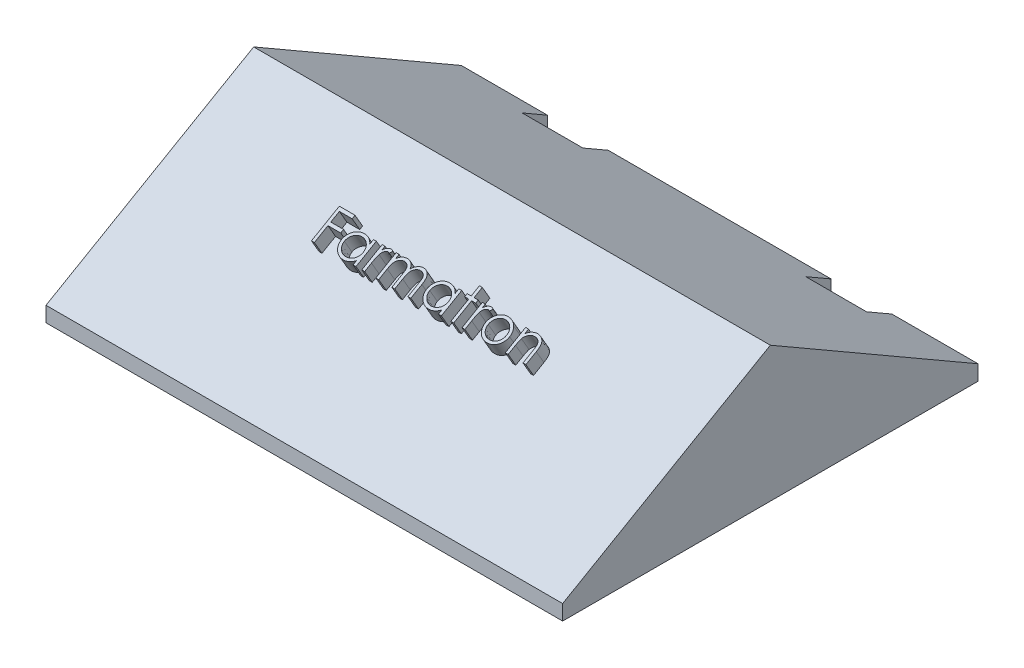
from build123d import *

# Parameters (mm, degrees)
SKETCH1_W                      = 102
SKETCH1_H                      = 82
BOSS_EXTRUDE1_DEPTH            = 3
SKETCH2_W                      = 91
SKETCH2_H                      = 71
BOSS_EXTRUDE2_DEPTH            = 3
BOSS_EXTRUDE4_DEPTH            = 102
BOSS_EXTRUDE5_DEPTH            = 3
SKETCH7_W                      = 12
SKETCH7_H                      = 7
CUT_EXTRUDE1_DEPTH             = 10
CUT_EXTRUDE1_DIRECTION_2_REACH = 28.671


with BuildPart() as part:
    # Sketch1 → Boss-Extrude1 (new body)
    with BuildSketch(Plane(origin=(0, 0, 0), x_dir=(1, 0, 0), z_dir=(0, 1, 0))):
        Rectangle(SKETCH1_W, SKETCH1_H)
    extrude(amount=BOSS_EXTRUDE1_DEPTH)

    # Sketch2 → Boss-Extrude2 (add)
    with BuildSketch(Plane.XZ):
        Rectangle(SKETCH2_W, SKETCH2_H)
    extrude(amount=BOSS_EXTRUDE2_DEPTH)

    # Sketch5 → Boss-Extrude4 (add)
    with BuildSketch(Plane.ZY.offset(51)):
        Polygon((-41, 3), (41, 3), (0, 26.671361037), align=None)
    extrude(amount=-BOSS_EXTRUDE4_DEPTH)

    # Sketch6 → Boss-Extrude5 (add)
    with BuildSketch(Plane(origin=(0, 20.003520778, 11.549038106), x_dir=(1, 0, 0), z_dir=(0, 0.866025404, 0.5))):
        Polygon((-19.990396317, -1.212207797), (-16.896806574, -1.212207797), (-16.896806574, -1.863489848), (-19.420524523, -1.863489848), (-19.420524523, -3.817336002), (-16.896806574, -3.817336002), (-16.896806574, -4.468618053), (-19.420524523, -4.468618053), (-19.420524523, -7.562207797), (-19.990396317, -7.562207797), align=None)
        with BuildLine():
            Line((-11.198088625, -2.921823181), (-11.198088625, -7.562207797))
            Line((-11.198088625, -7.562207797), (-11.76796042, -7.562207797))
            Line((-11.76796042, -7.562207797), (-11.76796042, -6.75955355))
            add(Edge.make_bspline(
                [(-11.76796042, -6.75955355), (-11.832220226, -6.832196813), (-11.957624045, -6.973961055), (-12.167067216, -7.159167282), (-12.389078053, -7.312253666), (-12.622579022, -7.435897084), (-12.867359263, -7.528774101), (-13.122876164, -7.594788989), (-13.389233955, -7.63723209), (-13.57112037, -7.641470301), (-13.663292952, -7.643618053)],
                knots=[0, 0, 0, 0, 0.000290762, 0.000567426, 0.000836293, 0.001098035, 0.001358135, 0.001619769, 0.001888723, 0.002165047, 0.002165047, 0.002165047, 0.002165047], degree=3))
            add(Edge.make_bspline(
                [(-13.663292952, -7.643618053), (-13.745240525, -7.641393063), (-13.906844769, -7.637005285), (-14.144568951, -7.602965106), (-14.373336318, -7.548299549), (-14.593363043, -7.472279364), (-14.803225364, -7.371439873), (-15.004720111, -7.250715038), (-15.196803423, -7.106949532), (-15.376547501, -6.942596966), (-15.542068416, -6.764080346), (-15.687322439, -6.57367914), (-15.808431599, -6.372216674), (-15.909705174, -6.162243667), (-15.987712827, -5.942143741), (-16.042093563, -5.712678022), (-16.076094088, -5.474117823), (-16.080480053, -5.311667545), (-16.08270401, -5.229295136)],
                knots=[0, 0, 0, 0, 0.00024577, 0.000484669, 0.00071884, 0.00095056, 0.001181567, 0.001416081, 0.001654206, 0.001900039, 0.002145792, 0.002383666, 0.00261709, 0.002849793, 0.003081935, 0.003316107, 0.003556266, 0.003803306, 0.003803306, 0.003803306, 0.003803306], degree=3))
            add(Edge.make_bspline(
                [(-16.08270401, -5.229295136), (-16.080430762, -5.148625274), (-16.075936673, -4.989145308), (-16.04245726, -4.754596814), (-15.986158144, -4.528685112), (-15.907149906, -4.312137515), (-15.805836645, -4.104691995), (-15.682595687, -3.906201836), (-15.537418132, -3.716120215), (-15.370045908, -3.538916703), (-15.188735682, -3.375230732), (-14.994772699, -3.23297432), (-14.792981889, -3.110116609), (-14.580233284, -3.012773873), (-14.359675822, -2.934017355), (-14.129345999, -2.87952897), (-13.890202135, -2.847420973), (-13.727840814, -2.842771387), (-13.645484458, -2.840412925)],
                knots=[0, 0, 0, 0, 0.000241958, 0.000478337, 0.000709106, 0.000939284, 0.001168551, 0.00140047, 0.001639115, 0.001884802, 0.002130726, 0.002370895, 0.002605409, 0.002838177, 0.003071519, 0.003306928, 0.003546915, 0.003793955, 0.003793955, 0.003793955, 0.003793955], degree=3))
            add(Edge.make_bspline(
                [(-13.645484458, -2.840412925), (-13.550779, -2.843021417), (-13.365066065, -2.848136547), (-13.093416677, -2.890704638), (-12.836433124, -2.962620143), (-12.592131657, -3.060441889), (-12.361389555, -3.190433155), (-12.146391284, -3.354408227), (-11.944886764, -3.551332952), (-11.82808252, -3.702590758), (-11.76796042, -3.780446979)],
                knots=[0, 0, 0, 0, 0.000284009, 0.000556928, 0.000822345, 0.001083124, 0.001344564, 0.001614238, 0.001892186, 0.002187002, 0.002187002, 0.002187002, 0.002187002], degree=3))
            Line((-11.76796042, -3.780446979), (-11.76796042, -2.921823181))
            Line((-11.76796042, -2.921823181), (-11.198088625, -2.921823181))
        make_face()
        with BuildLine():
            add(Edge.make_bspline(
                [(-13.637852247, -3.41028472), (-13.721153974, -3.413248605), (-13.885578334, -3.419098844), (-14.126958166, -3.464770757), (-14.357941075, -3.540761378), (-14.57737181, -3.644687113), (-14.781784145, -3.775367821), (-14.964471234, -3.933430902), (-15.126927278, -4.11456377), (-15.263557986, -4.317949028), (-15.374937887, -4.535986422), (-15.453255217, -4.763905045), (-15.504906566, -4.997594076), (-15.510183453, -5.156094949), (-15.512832215, -5.235655313)],
                knots=[0, 0, 0, 0, 0.000249786, 0.000493037, 0.00073399, 0.000977521, 0.001219572, 0.001459505, 0.001700041, 0.001947359, 0.002192545, 0.00243231, 0.002668812, 0.002907172, 0.002907172, 0.002907172, 0.002907172], degree=3))
            add(Edge.make_bspline(
                [(-15.512832215, -5.235655313), (-15.509448766, -5.314740221), (-15.502695129, -5.472600053), (-15.454161726, -5.706607671), (-15.372736813, -5.934580004), (-15.261626214, -6.154582092), (-15.122494766, -6.358841817), (-14.961225353, -6.543427468), (-14.776258414, -6.702158578), (-14.571375652, -6.835032462), (-14.352558334, -6.942370178), (-14.122445344, -7.01705641), (-13.8853624, -7.065276098), (-13.72415888, -7.070908506), (-13.642940388, -7.073746258)],
                knots=[0, 0, 0, 0, 0.000237176, 0.000473422, 0.000713608, 0.000961638, 0.001210723, 0.001453162, 0.001694889, 0.001939391, 0.002184022, 0.002423766, 0.002663507, 0.002906945, 0.002906945, 0.002906945, 0.002906945], degree=3))
            add(Edge.make_bspline(
                [(-13.642940388, -7.073746258), (-13.560487447, -7.070734609), (-13.396496726, -7.064744739), (-13.154400785, -7.0188773), (-12.919459923, -6.943096766), (-12.694874523, -6.838051207), (-12.485658114, -6.707862862), (-12.297883393, -6.555449997), (-12.139104422, -6.378188505), (-12.00449783, -6.183376941), (-11.898951003, -5.969813747), (-11.822068724, -5.742421715), (-11.776613781, -5.501192929), (-11.770884757, -5.336339805), (-11.76796042, -5.252191771)],
                knots=[0, 0, 0, 0, 0.000247246, 0.000491749, 0.00073633, 0.000986158, 0.001233581, 0.001473979, 0.001709031, 0.001945074, 0.002182295, 0.002421234, 0.002663235, 0.00291556, 0.00291556, 0.00291556, 0.00291556], degree=3))
            add(Edge.make_bspline(
                [(-11.76796042, -5.252191771), (-11.769701511, -5.18807885), (-11.773128529, -5.061884332), (-11.799309705, -4.876595836), (-11.8409565, -4.699278933), (-11.899641694, -4.529747197), (-11.976733024, -4.368937955), (-12.069711114, -4.215696562), (-12.180211001, -4.070820021), (-12.306453893, -3.936303306), (-12.444639332, -3.813609582), (-12.590860855, -3.704091602), (-12.746850868, -3.614123401), (-12.909986063, -3.539662808), (-13.080549484, -3.480409779), (-13.259929037, -3.440880677), (-13.446218057, -3.413738381), (-13.573301614, -3.411448061), (-13.637852247, -3.41028472)],
                knots=[0, 0, 0, 0, 0.000192284, 0.000378475, 0.000560202, 0.000738015, 0.000915535, 0.001094205, 0.001274839, 0.001461134, 0.001646738, 0.001828644, 0.002008199, 0.002185797, 0.002366014, 0.002548692, 0.002736143, 0.002929643, 0.002929643, 0.002929643, 0.002929643], degree=3))
        make_face(mode=Mode.SUBTRACT)
        with BuildLine():
            Line((-10.058345035, -2.921823181), (-9.488473241, -2.921823181))
            Line((-9.488473241, -2.921823181), (-9.488473241, -3.604906114))
            add(Edge.make_bspline(
                [(-9.488473241, -3.604906114), (-9.446402207, -3.541304825), (-9.365941682, -3.419667855), (-9.232205367, -3.258796409), (-9.095220752, -3.125600539), (-8.954332055, -3.019458441), (-8.808503216, -2.939968925), (-8.660934747, -2.88174299), (-8.509304966, -2.847312718), (-8.407411189, -2.842715937), (-8.356361862, -2.840412925)],
                knots=[0, 0, 0, 0, 0.000228641, 0.000437274, 0.000626196, 0.00080072, 0.000964674, 0.001122945, 0.001275403, 0.001428476, 0.001428476, 0.001428476, 0.001428476], degree=3))
            add(Edge.make_bspline(
                [(-8.356361862, -2.840412925), (-8.31676267, -2.84257288), (-8.235284758, -2.847017129), (-8.111944917, -2.878242482), (-7.984866083, -2.928095466), (-7.902964894, -2.974977013), (-7.860268112, -2.999417332)],
                knots=[0, 0, 0, 0, 0.000118736, 0.000244307, 0.000379658, 0.000527066, 0.000527066, 0.000527066, 0.000527066], degree=3))
            Line((-7.860268112, -2.999417332), (-8.173188785, -3.492967011))
            add(Edge.make_bspline(
                [(-8.173188785, -3.492967011), (-8.200600867, -3.480738243), (-8.252634244, -3.457525699), (-8.328751815, -3.430053767), (-8.398930811, -3.413877748), (-8.443641267, -3.41142716), (-8.464484859, -3.41028472)],
                knots=[0, 0, 0, 0, 9.0027e-05, 0.000170889, 0.000242497, 0.000305034, 0.000305034, 0.000305034, 0.000305034], degree=3))
            add(Edge.make_bspline(
                [(-8.464484859, -3.41028472), (-8.510215261, -3.413332788), (-8.603492026, -3.419549962), (-8.740442475, -3.468424656), (-8.873333833, -3.547391878), (-8.978873849, -3.634969466), (-9.060593365, -3.71942047), (-9.118904917, -3.793168286), (-9.172395044, -3.875860947), (-9.223503872, -3.966084801), (-9.270069863, -4.065380379), (-9.313530477, -4.172755638), (-9.352825843, -4.288334943), (-9.375232715, -4.368857515), (-9.38671042, -4.410104431)],
                knots=[0, 0, 0, 0, 0.000136961, 0.000279361, 0.000430989, 0.000599071, 0.000689036, 0.000783201, 0.000880576, 0.000984237, 0.001094053, 0.001209325, 0.001331612, 0.001460037, 0.001460037, 0.001460037, 0.001460037], degree=3))
            add(Edge.make_bspline(
                [(-9.38671042, -4.410104431), (-9.395296334, -4.446893018), (-9.41431348, -4.528376941), (-9.432803842, -4.665080693), (-9.451072824, -4.826595045), (-9.463948117, -5.013369578), (-9.475882565, -5.224937869), (-9.482613714, -5.461622228), (-9.488243698, -5.723665593), (-9.488394405, -5.90686192), (-9.488473241, -6.002692572)],
                knots=[0, 0, 0, 0, 0.000113275, 0.000250896, 0.000413424, 0.000600936, 0.000812404, 0.001049125, 0.001311214, 0.001598697, 0.001598697, 0.001598697, 0.001598697], degree=3))
            Line((-9.488473241, -6.002692572), (-9.488473241, -7.562207797))
            Line((-9.488473241, -7.562207797), (-10.058345035, -7.562207797))
            Line((-10.058345035, -7.562207797), (-10.058345035, -2.921823181))
        make_face()
        with BuildLine():
            Line((-7.290396317, -2.921823181), (-6.720524523, -2.921823181))
            Line((-6.720524523, -2.921823181), (-6.720524523, -3.728293534))
            add(Edge.make_bspline(
                [(-6.720524523, -3.728293534), (-6.669209356, -3.657740314), (-6.570884578, -3.52255358), (-6.409656894, -3.34440835), (-6.248591662, -3.193227269), (-6.13259824, -3.113865202), (-6.076874683, -3.075739447)],
                knots=[0, 0, 0, 0, 0.000261532, 0.000501121, 0.000719915, 0.000922205, 0.000922205, 0.000922205, 0.000922205], degree=3))
            add(Edge.make_bspline(
                [(-6.076874683, -3.075739447), (-6.000920224, -3.039443999), (-5.85033832, -2.967487226), (-5.611906298, -2.894492055), (-5.367930826, -2.849633657), (-5.203178781, -2.843498879), (-5.12030417, -2.840412925)],
                knots=[0, 0, 0, 0, 0.000252242, 0.000500077, 0.000745602, 0.000994118, 0.000994118, 0.000994118, 0.000994118], degree=3))
            add(Edge.make_bspline(
                [(-5.12030417, -2.840412925), (-5.064255448, -2.842309381), (-4.95333804, -2.846062366), (-4.788992619, -2.870482715), (-4.629591995, -2.912694201), (-4.47607797, -2.971490345), (-4.331441881, -3.042695049), (-4.198837193, -3.126242376), (-4.07977613, -3.220035641), (-3.974318866, -3.328310277), (-3.879487919, -3.454106677), (-3.792259155, -3.600817529), (-3.711659127, -3.771737142), (-3.666989038, -3.895773581), (-3.643471237, -3.961075986)],
                knots=[0, 0, 0, 0, 0.000168145, 0.000332749, 0.000497201, 0.000661865, 0.000825132, 0.000980059, 0.001131239, 0.001278762, 0.001432173, 0.001602768, 0.001789969, 0.001998105, 0.001998105, 0.001998105, 0.001998105], degree=3))
            add(Edge.make_bspline(
                [(-3.643471237, -3.961075986), (-3.61859511, -3.916218825), (-3.569642384, -3.827946232), (-3.487445014, -3.703017671), (-3.401324869, -3.586165349), (-3.310548003, -3.47729655), (-3.215434824, -3.376948896), (-3.115537712, -3.284790618), (-3.011425323, -3.200425944), (-2.866659402, -3.101868212), (-2.678313672, -2.997181783), (-2.440845235, -2.906415892), (-2.193829924, -2.850325202), (-2.026157814, -2.843738849), (-1.941488064, -2.840412925)],
                knots=[0, 0, 0, 0, 0.000153832, 0.00030272, 0.000448244, 0.000589125, 0.000727689, 0.000862717, 0.000996613, 0.001129277, 0.001387748, 0.001640998, 0.001889761, 0.002143522, 0.002143522, 0.002143522, 0.002143522], degree=3))
            add(Edge.make_bspline(
                [(-1.941488064, -2.840412925), (-1.863688839, -2.843347026), (-1.711428201, -2.849089346), (-1.489763733, -2.894180647), (-1.283040743, -2.971610093), (-1.091675191, -3.077262548), (-0.919028101, -3.210030494), (-0.768957083, -3.367998243), (-0.642373709, -3.55004843), (-0.559681035, -3.721302467), (-0.503591912, -3.872496571), (-0.469009387, -4.001322271), (-0.438457369, -4.143111517), (-0.413091395, -4.298033848), (-0.394552022, -4.466636523), (-0.380816581, -4.648643627), (-0.371520048, -4.844196615), (-0.370863145, -4.97911688), (-0.370524523, -5.04866613)],
                knots=[0, 0, 0, 0, 0.000233282, 0.000456556, 0.000675113, 0.000893181, 0.001109954, 0.001325893, 0.001544317, 0.00177244, 0.001894377, 0.002027698, 0.002172157, 0.002329416, 0.002498406, 0.002680844, 0.00287694, 0.003085569, 0.003085569, 0.003085569, 0.003085569], degree=3))
            Line((-0.370524523, -5.04866613), (-0.370524523, -7.562207797))
            Line((-0.370524523, -7.562207797), (-0.940396317, -7.562207797))
            Line((-0.940396317, -7.562207797), (-0.940396317, -5.046122059))
            add(Edge.make_bspline(
                [(-0.940396317, -5.046122059), (-0.940537619, -4.98675759), (-0.94080918, -4.872668107), (-0.945696198, -4.708924374), (-0.954904267, -4.559666069), (-0.965671398, -4.425096709), (-0.980628023, -4.304902478), (-0.999942785, -4.199324805), (-1.020403719, -4.107533175), (-1.05439616, -4.00577706), (-1.108730192, -3.893526821), (-1.191493334, -3.772471191), (-1.295760527, -3.667096025), (-1.416156811, -3.575622793), (-1.553223275, -3.501248616), (-1.704289272, -3.448133569), (-1.868416909, -3.41525349), (-1.982032539, -3.411976862), (-2.040706814, -3.41028472)],
                knots=[0, 0, 0, 0, 0.000178089, 0.000342261, 0.000491355, 0.000626676, 0.000747218, 0.000854507, 0.000948612, 0.001029062, 0.001175849, 0.001321223, 0.001466947, 0.001618576, 0.001773394, 0.001932718, 0.002097367, 0.002273203, 0.002273203, 0.002273203, 0.002273203], degree=3))
            add(Edge.make_bspline(
                [(-2.040706814, -3.41028472), (-2.112679446, -3.412854034), (-2.254924727, -3.417931975), (-2.462561538, -3.469773145), (-2.662080383, -3.547933028), (-2.847527838, -3.661203343), (-3.018121115, -3.796927089), (-3.164896064, -3.95830707), (-3.286148743, -4.140878509), (-3.368252385, -4.30987324), (-3.420121546, -4.461673517), (-3.454369665, -4.594293035), (-3.481009532, -4.745026736), (-3.505993207, -4.912861755), (-3.522299513, -5.098953368), (-3.537119274, -5.302440753), (-3.544051411, -5.523935937), (-3.545021072, -5.677472929), (-3.545524523, -5.757189768)],
                knots=[0, 0, 0, 0, 0.000215515, 0.00042594, 0.000638294, 0.000856228, 0.001075151, 0.001290351, 0.001507675, 0.001730699, 0.001851783, 0.00198846, 0.002141147, 0.002310786, 0.002497355, 0.002701361, 0.002922827, 0.003161983, 0.003161983, 0.003161983, 0.003161983], degree=3))
            Line((-3.545524523, -5.757189768), (-3.545524523, -7.562207797))
            Line((-3.545524523, -7.562207797), (-4.115396317, -7.562207797))
            Line((-4.115396317, -7.562207797), (-4.115396317, -5.202582396))
            add(Edge.make_bspline(
                [(-4.115396317, -5.202582396), (-4.115540428, -5.136010232), (-4.115817682, -5.00793208), (-4.120673286, -4.824265269), (-4.129901871, -4.657203881), (-4.140570866, -4.506942082), (-4.155920047, -4.373752957), (-4.173354901, -4.256922467), (-4.193944523, -4.156743505), (-4.228034743, -4.046864221), (-4.280130992, -3.925813403), (-4.363929696, -3.796743265), (-4.468446306, -3.683771145), (-4.591039181, -3.587325987), (-4.728935204, -3.507603585), (-4.881305089, -3.45016375), (-5.046776859, -3.416736825), (-5.160854983, -3.412475981), (-5.21952292, -3.41028472)],
                knots=[0, 0, 0, 0, 0.000199714, 0.000384229, 0.000551103, 0.000701639, 0.000836072, 0.00095319, 0.001055981, 0.001142488, 0.001297994, 0.001449708, 0.001601848, 0.001757598, 0.001916006, 0.00207784, 0.002243986, 0.002419899, 0.002419899, 0.002419899, 0.002419899], degree=3))
            add(Edge.make_bspline(
                [(-5.21952292, -3.41028472), (-5.288495189, -3.413061411), (-5.425954473, -3.41859526), (-5.627888046, -3.468405156), (-5.822897787, -3.546426835), (-6.00787274, -3.654666792), (-6.177824409, -3.788740835), (-6.326610837, -3.946429289), (-6.451692276, -4.125769678), (-6.534662855, -4.292982444), (-6.588181515, -4.440979671), (-6.623733051, -4.566802105), (-6.654284943, -4.706502555), (-6.676988954, -4.860512028), (-6.698906279, -5.027827442), (-6.709484126, -5.209282302), (-6.71977396, -5.404720947), (-6.720268198, -5.539653993), (-6.720524523, -5.609633678)],
                knots=[0, 0, 0, 0, 0.000206634, 0.000411815, 0.000620153, 0.000835052, 0.001052387, 0.001267452, 0.001483061, 0.001706059, 0.001825169, 0.001954817, 0.002098033, 0.002253835, 0.00242171, 0.002604055, 0.00279888, 0.003008781, 0.003008781, 0.003008781, 0.003008781], degree=3))
            Line((-6.720524523, -5.609633678), (-6.720524523, -7.562207797))
            Line((-6.720524523, -7.562207797), (-7.290396317, -7.562207797))
            Line((-7.290396317, -7.562207797), (-7.290396317, -2.921823181))
        make_face()
        with BuildLine():
            Line((5.653834452, -2.921823181), (5.653834452, -7.562207797))
            Line((5.653834452, -7.562207797), (5.083962657, -7.562207797))
            Line((5.083962657, -7.562207797), (5.083962657, -6.75955355))
            add(Edge.make_bspline(
                [(5.083962657, -6.75955355), (5.019702851, -6.832196813), (4.894299032, -6.973961055), (4.684855861, -7.159167282), (4.462845024, -7.312253666), (4.229344055, -7.435897084), (3.984563814, -7.528774101), (3.729046913, -7.594788989), (3.462689122, -7.63723209), (3.280802707, -7.641470301), (3.188630125, -7.643618053)],
                knots=[0, 0, 0, 0, 0.000290762, 0.000567426, 0.000836293, 0.001098035, 0.001358135, 0.001619769, 0.001888723, 0.002165047, 0.002165047, 0.002165047, 0.002165047], degree=3))
            add(Edge.make_bspline(
                [(3.188630125, -7.643618053), (3.106682552, -7.641393063), (2.945078308, -7.637005285), (2.707354126, -7.602965106), (2.478586759, -7.548299549), (2.258560034, -7.472279364), (2.048697713, -7.371439873), (1.847202966, -7.250715038), (1.655119654, -7.106949532), (1.475375576, -6.942596966), (1.309854661, -6.764080346), (1.164600638, -6.57367914), (1.043491478, -6.372216674), (0.942217903, -6.162243667), (0.86421025, -5.942143741), (0.809829513, -5.712678022), (0.775828989, -5.474117823), (0.771443024, -5.311667545), (0.769219067, -5.229295136)],
                knots=[0, 0, 0, 0, 0.00024577, 0.000484669, 0.00071884, 0.00095056, 0.001181567, 0.001416081, 0.001654206, 0.001900039, 0.002145792, 0.002383666, 0.00261709, 0.002849793, 0.003081935, 0.003316107, 0.003556266, 0.003803306, 0.003803306, 0.003803306, 0.003803306], degree=3))
            add(Edge.make_bspline(
                [(0.769219067, -5.229295136), (0.771492315, -5.148625274), (0.775986404, -4.989145308), (0.809465817, -4.754596814), (0.865764933, -4.528685112), (0.944773171, -4.312137515), (1.046086432, -4.104691995), (1.16932739, -3.906201836), (1.314504945, -3.716120215), (1.481877169, -3.538916703), (1.663187395, -3.375230732), (1.857150378, -3.23297432), (2.058941188, -3.110116609), (2.271689793, -3.012773873), (2.492247255, -2.934017355), (2.722577078, -2.87952897), (2.961720942, -2.847420973), (3.124082263, -2.842771387), (3.206438618, -2.840412925)],
                knots=[0, 0, 0, 0, 0.000241958, 0.000478337, 0.000709106, 0.000939284, 0.001168551, 0.00140047, 0.001639115, 0.001884802, 0.002130726, 0.002370895, 0.002605409, 0.002838177, 0.003071519, 0.003306928, 0.003546915, 0.003793955, 0.003793955, 0.003793955, 0.003793955], degree=3))
            add(Edge.make_bspline(
                [(3.206438618, -2.840412925), (3.301144077, -2.843021417), (3.486857012, -2.848136547), (3.7585064, -2.890704638), (4.015489953, -2.962620143), (4.25979142, -3.060441889), (4.490533522, -3.190433155), (4.705531793, -3.354408227), (4.907036313, -3.551332952), (5.023840556, -3.702590758), (5.083962657, -3.780446979)],
                knots=[0, 0, 0, 0, 0.000284009, 0.000556928, 0.000822345, 0.001083124, 0.001344564, 0.001614238, 0.001892186, 0.002187002, 0.002187002, 0.002187002, 0.002187002], degree=3))
            Line((5.083962657, -3.780446979), (5.083962657, -2.921823181))
            Line((5.083962657, -2.921823181), (5.653834452, -2.921823181))
        make_face()
        with BuildLine():
            add(Edge.make_bspline(
                [(3.21407083, -3.41028472), (3.130769103, -3.413248605), (2.966344743, -3.419098844), (2.72496491, -3.464770757), (2.493982002, -3.540761378), (2.274551267, -3.644687113), (2.070138931, -3.775367821), (1.887451843, -3.933430902), (1.724995799, -4.11456377), (1.588365091, -4.317949028), (1.47698519, -4.535986422), (1.39866786, -4.763905045), (1.347016511, -4.997594076), (1.341739624, -5.156094949), (1.339090862, -5.235655313)],
                knots=[0, 0, 0, 0, 0.000249786, 0.000493037, 0.00073399, 0.000977521, 0.001219572, 0.001459505, 0.001700041, 0.001947359, 0.002192545, 0.00243231, 0.002668812, 0.002907172, 0.002907172, 0.002907172, 0.002907172], degree=3))
            add(Edge.make_bspline(
                [(1.339090862, -5.235655313), (1.342474311, -5.314740221), (1.349227948, -5.472600053), (1.397761351, -5.706607671), (1.479186264, -5.934580004), (1.590296863, -6.154582092), (1.729428311, -6.358841817), (1.890697724, -6.543427468), (2.075664663, -6.702158578), (2.280547425, -6.835032462), (2.499364743, -6.942370178), (2.729477733, -7.01705641), (2.966560677, -7.065276098), (3.127764197, -7.070908506), (3.208982689, -7.073746258)],
                knots=[0, 0, 0, 0, 0.000237176, 0.000473422, 0.000713608, 0.000961638, 0.001210723, 0.001453162, 0.001694889, 0.001939391, 0.002184022, 0.002423766, 0.002663507, 0.002906945, 0.002906945, 0.002906945, 0.002906945], degree=3))
            add(Edge.make_bspline(
                [(3.208982689, -7.073746258), (3.29143563, -7.070734609), (3.455426351, -7.064744739), (3.697522292, -7.0188773), (3.932463153, -6.943096766), (4.157048554, -6.838051207), (4.366264963, -6.707862862), (4.554039684, -6.555449997), (4.712818655, -6.378188505), (4.847425247, -6.183376941), (4.952972074, -5.969813747), (5.029854353, -5.742421715), (5.075309296, -5.501192929), (5.08103832, -5.336339805), (5.083962657, -5.252191771)],
                knots=[0, 0, 0, 0, 0.000247246, 0.000491749, 0.00073633, 0.000986158, 0.001233581, 0.001473979, 0.001709031, 0.001945074, 0.002182295, 0.002421234, 0.002663235, 0.00291556, 0.00291556, 0.00291556, 0.00291556], degree=3))
            add(Edge.make_bspline(
                [(5.083962657, -5.252191771), (5.082221566, -5.18807885), (5.078794548, -5.061884332), (5.052613372, -4.876595836), (5.010966577, -4.699278933), (4.952281383, -4.529747197), (4.875190053, -4.368937955), (4.782211963, -4.215696562), (4.671712076, -4.070820021), (4.545469184, -3.936303306), (4.407283745, -3.813609582), (4.261062222, -3.704091602), (4.105072209, -3.614123401), (3.941937014, -3.539662808), (3.771373593, -3.480409779), (3.59199404, -3.440880677), (3.40570502, -3.413738381), (3.278621463, -3.411448061), (3.21407083, -3.41028472)],
                knots=[0, 0, 0, 0, 0.000192284, 0.000378475, 0.000560202, 0.000738015, 0.000915535, 0.001094205, 0.001274839, 0.001461134, 0.001646738, 0.001828644, 0.002008199, 0.002185797, 0.002366014, 0.002548692, 0.002736143, 0.002929643, 0.002929643, 0.002929643, 0.002929643], degree=3))
        make_face(mode=Mode.SUBTRACT)
        Polygon((7.526270349, -1.049387284), (8.096142144, -1.049387284), (8.096142144, -2.921823181), (8.910244708, -2.921823181), (8.910244708, -3.491694976), (8.096142144, -3.491694976), (8.096142144, -7.562207797), (7.526270349, -7.562207797), (7.526270349, -3.491694976), (6.712167785, -3.491694976), (6.712167785, -2.921823181), (7.526270349, -2.921823181), align=None)
        with BuildLine():
            Line((9.724347272, -2.921823181), (10.294219067, -2.921823181))
            Line((10.294219067, -2.921823181), (10.294219067, -3.604906114))
            add(Edge.make_bspline(
                [(10.294219067, -3.604906114), (10.336290101, -3.541304825), (10.416750626, -3.419667855), (10.550486941, -3.258796409), (10.687471556, -3.125600539), (10.828360253, -3.019458441), (10.974189091, -2.939968925), (11.121757561, -2.88174299), (11.273387342, -2.847312718), (11.375281119, -2.842715937), (11.426330445, -2.840412925)],
                knots=[0, 0, 0, 0, 0.000228641, 0.000437274, 0.000626196, 0.00080072, 0.000964674, 0.001122945, 0.001275403, 0.001428476, 0.001428476, 0.001428476, 0.001428476], degree=3))
            add(Edge.make_bspline(
                [(11.426330445, -2.840412925), (11.465929638, -2.84257288), (11.547407549, -2.847017129), (11.670747391, -2.878242482), (11.797826225, -2.928095466), (11.879727413, -2.974977013), (11.922424195, -2.999417332)],
                knots=[0, 0, 0, 0, 0.000118736, 0.000244307, 0.000379658, 0.000527066, 0.000527066, 0.000527066, 0.000527066], degree=3))
            Line((11.922424195, -2.999417332), (11.609503522, -3.492967011))
            add(Edge.make_bspline(
                [(11.609503522, -3.492967011), (11.582091441, -3.480738243), (11.530058063, -3.457525699), (11.453940493, -3.430053767), (11.383761496, -3.413877748), (11.339051041, -3.41142716), (11.318207449, -3.41028472)],
                knots=[0, 0, 0, 0, 9.0027e-05, 0.000170889, 0.000242497, 0.000305034, 0.000305034, 0.000305034, 0.000305034], degree=3))
            add(Edge.make_bspline(
                [(11.318207449, -3.41028472), (11.272477046, -3.413332788), (11.179200282, -3.419549962), (11.042249833, -3.468424656), (10.909358474, -3.547391878), (10.803818458, -3.634969466), (10.722098942, -3.71942047), (10.66378739, -3.793168286), (10.610297264, -3.875860947), (10.559188435, -3.966084801), (10.512622444, -4.065380379), (10.46916183, -4.172755638), (10.429866465, -4.288334943), (10.407459593, -4.368857515), (10.395981888, -4.410104431)],
                knots=[0, 0, 0, 0, 0.000136961, 0.000279361, 0.000430989, 0.000599071, 0.000689036, 0.000783201, 0.000880576, 0.000984237, 0.001094053, 0.001209325, 0.001331612, 0.001460037, 0.001460037, 0.001460037, 0.001460037], degree=3))
            add(Edge.make_bspline(
                [(10.395981888, -4.410104431), (10.387395974, -4.446893018), (10.368378828, -4.528376941), (10.349888466, -4.665080693), (10.331619484, -4.826595045), (10.31874419, -5.013369578), (10.306809742, -5.224937869), (10.300078593, -5.461622228), (10.29444861, -5.723665593), (10.294297903, -5.90686192), (10.294219067, -6.002692572)],
                knots=[0, 0, 0, 0, 0.000113275, 0.000250896, 0.000413424, 0.000600936, 0.000812404, 0.001049125, 0.001311214, 0.001598697, 0.001598697, 0.001598697, 0.001598697], degree=3))
            Line((10.294219067, -6.002692572), (10.294219067, -7.562207797))
            Line((10.294219067, -7.562207797), (9.724347272, -7.562207797))
            Line((9.724347272, -7.562207797), (9.724347272, -2.921823181))
        make_face()
        with BuildLine():
            add(Edge.make_bspline(
                [(14.733622112, -2.840412925), (14.820691993, -2.842266927), (14.99141475, -2.845902173), (15.241437629, -2.884755039), (15.48009809, -2.944168115), (15.708310181, -3.026303663), (15.923151174, -3.136398059), (16.127750432, -3.267769202), (16.321547005, -3.423403336), (16.437703072, -3.543795831), (16.496662977, -3.604906114)],
                knots=[0, 0, 0, 0, 0.000261018, 0.000511793, 0.000757062, 0.000998109, 0.001237606, 0.001479657, 0.001726593, 0.001981143, 0.001981143, 0.001981143, 0.001981143], degree=3))
            add(Edge.make_bspline(
                [(16.496662977, -3.604906114), (16.547430237, -3.663351488), (16.64798227, -3.779111158), (16.776915788, -3.966809198), (16.88798919, -4.161191952), (16.977003419, -4.364840673), (17.047189105, -4.575977577), (17.097019725, -4.795328369), (17.126659593, -5.022408627), (17.130656405, -5.176629876), (17.132680606, -5.254735842)],
                knots=[0, 0, 0, 0, 0.000232086, 0.000459681, 0.000681833, 0.000902819, 0.001125265, 0.001348369, 0.001576673, 0.001810949, 0.001810949, 0.001810949, 0.001810949], degree=3))
            add(Edge.make_bspline(
                [(17.132680606, -5.254735842), (17.130900179, -5.333294518), (17.127381974, -5.488530125), (17.094101413, -5.71716526), (17.042337871, -5.938861581), (16.968257251, -6.152690926), (16.873264681, -6.359306913), (16.757348719, -6.557807095), (16.619695928, -6.748583108), (16.463660105, -6.930015015), (16.291208844, -7.097230862), (16.10412669, -7.242969293), (15.906090086, -7.367831202), (15.694465716, -7.468408699), (15.471186133, -7.547710584), (15.235769738, -7.603409185), (14.988582253, -7.637085383), (14.819804294, -7.641409866), (14.733622112, -7.643618053)],
                knots=[0, 0, 0, 0, 0.000235546, 0.000465451, 0.000691608, 0.000917687, 0.001143082, 0.001372814, 0.001606155, 0.001847882, 0.00208988, 0.002325505, 0.002558096, 0.002790799, 0.003026963, 0.003267616, 0.003515337, 0.003773814, 0.003773814, 0.003773814, 0.003773814], degree=3))
            add(Edge.make_bspline(
                [(14.733622112, -7.643618053), (14.647017692, -7.641402454), (14.477398561, -7.637063092), (14.229338565, -7.603540022), (13.993500257, -7.547736253), (13.769928371, -7.468148088), (13.557394149, -7.367827987), (13.358210075, -7.243346779), (13.170975943, -7.09718764), (12.9984882, -6.930026726), (12.842462159, -6.748580091), (12.704806844, -6.557807878), (12.588891538, -6.359306709), (12.493898796, -6.15269098), (12.419818221, -5.938861567), (12.368054668, -5.717165264), (12.33477411, -5.488530124), (12.331255904, -5.333294517), (12.329475477, -5.254735842)],
                knots=[0, 0, 0, 0, 0.000259748, 0.000508729, 0.000749382, 0.000985546, 0.001219397, 0.001453067, 0.001688693, 0.00193069, 0.002172417, 0.002405759, 0.00263549, 0.002860885, 0.003086964, 0.003313122, 0.003543026, 0.003778572, 0.003778572, 0.003778572, 0.003778572], degree=3))
            add(Edge.make_bspline(
                [(12.329475477, -5.254735842), (12.331513483, -5.177054394), (12.335548385, -5.023258478), (12.365158451, -4.796605097), (12.41479469, -4.577625548), (12.485064509, -4.367303613), (12.574899212, -4.164547322), (12.684411835, -3.969684271), (12.814660554, -3.782834976), (12.914812666, -3.667224917), (12.965493106, -3.60872222)],
                knots=[0, 0, 0, 0, 0.000233005, 0.000461309, 0.000684413, 0.000905652, 0.001125475, 0.001348734, 0.001575285, 0.001807372, 0.001807372, 0.001807372, 0.001807372], degree=3))
            add(Edge.make_bspline(
                [(12.965493106, -3.60872222), (13.024364121, -3.547081973), (13.140144331, -3.425855581), (13.334905594, -3.270675145), (13.539001527, -3.136570268), (13.75621675, -3.02866342), (13.984241364, -2.943684966), (14.224124846, -2.884601817), (14.474996139, -2.846042159), (14.646554308, -2.842308036), (14.733622112, -2.840412925)],
                knots=[0, 0, 0, 0, 0.000255448, 0.000502383, 0.000745126, 0.000986896, 0.001228382, 0.00147365, 0.001726942, 0.00198796, 0.00198796, 0.00198796, 0.00198796], degree=3))
        make_face()
        with BuildLine():
            add(Edge.make_bspline(
                [(14.731078042, -3.41028472), (14.669505518, -3.412034765), (14.547949956, -3.415489677), (14.369025852, -3.441767619), (14.196777287, -3.483400948), (14.03087747, -3.542554021), (13.871885857, -3.618933452), (13.719650227, -3.712747191), (13.573722801, -3.822752698), (13.4369582, -3.948777831), (13.311441719, -4.086444006), (13.20171739, -4.233126029), (13.108417555, -4.386444686), (13.030693266, -4.546559412), (12.972804511, -4.715092791), (12.930762027, -4.890136222), (12.904508876, -5.072046335), (12.901086447, -5.195709897), (12.899347272, -5.258551947)],
                knots=[0, 0, 0, 0, 0.00018466, 0.000364553, 0.000541334, 0.000715547, 0.00089192, 0.001069504, 0.001251152, 0.001439314, 0.001626619, 0.001809283, 0.001987953, 0.002164326, 0.002342139, 0.002521392, 0.002703804, 0.002892275, 0.002892275, 0.002892275, 0.002892275], degree=3))
            add(Edge.make_bspline(
                [(12.899347272, -5.258551947), (12.902262509, -5.339744911), (12.90804871, -5.500897761), (12.955102639, -5.738226512), (13.033817747, -5.966067872), (13.140111811, -6.183086173), (13.273291665, -6.383877306), (13.430203915, -6.56289557), (13.609164514, -6.717446971), (13.808040165, -6.845682219), (14.022768713, -6.947572062), (14.250019467, -7.019778775), (14.487039012, -7.066717417), (14.649019767, -7.071382806), (14.731078042, -7.073746258)],
                knots=[0, 0, 0, 0, 0.000243438, 0.000483178, 0.000722527, 0.000964873, 0.001206187, 0.00144324, 0.001676828, 0.001913224, 0.002151068, 0.002387605, 0.002627106, 0.002873007, 0.002873007, 0.002873007, 0.002873007], degree=3))
            add(Edge.make_bspline(
                [(14.731078042, -7.073746258), (14.813131597, -7.071369035), (14.975103035, -7.066676464), (15.211793256, -7.020015177), (15.438422891, -6.947255678), (15.652928408, -6.845796811), (15.851713531, -6.716960002), (16.031961223, -6.563768289), (16.187533703, -6.383403159), (16.320581815, -6.182820214), (16.428616619, -5.966404318), (16.506963285, -5.738184461), (16.554130334, -5.50090847), (16.559901266, -5.339748499), (16.562808811, -5.258551947)],
                knots=[0, 0, 0, 0, 0.000245901, 0.000485402, 0.000720729, 0.000958572, 0.001194969, 0.001429521, 0.001665736, 0.001907051, 0.002149959, 0.002389308, 0.002629049, 0.002872487, 0.002872487, 0.002872487, 0.002872487], degree=3))
            add(Edge.make_bspline(
                [(16.562808811, -5.258551947), (16.561070235, -5.195709521), (16.557648984, -5.07204522), (16.531387263, -4.890140483), (16.489376498, -4.715077158), (16.431370849, -4.546617095), (16.353984281, -4.386030123), (16.258885243, -4.233576189), (16.149608954, -4.085935884), (16.022577891, -3.94922285), (15.885956049, -3.82270357), (15.739969479, -3.712704535), (15.58795959, -3.619345754), (15.429429875, -3.541900718), (15.263508788, -3.483939114), (15.091501568, -3.441527226), (14.91334087, -3.415600726), (14.792220892, -3.412068055), (14.731078042, -3.41028472)],
                knots=[0, 0, 0, 0, 0.000188472, 0.000370883, 0.000550137, 0.000727949, 0.000904322, 0.001083656, 0.001266321, 0.001454483, 0.001642645, 0.001824293, 0.002001877, 0.002177105, 0.002352516, 0.002528062, 0.002707955, 0.002891344, 0.002891344, 0.002891344, 0.002891344], degree=3))
        make_face(mode=Mode.SUBTRACT)
        with BuildLine():
            Line((18.272424195, -2.921823181), (18.84229599, -2.921823181))
            Line((18.84229599, -2.921823181), (18.84229599, -3.75882238))
            add(Edge.make_bspline(
                [(18.84229599, -3.75882238), (18.903142843, -3.682907726), (19.021218282, -3.535592691), (19.21785843, -3.341971077), (19.425673792, -3.182413311), (19.643391712, -3.055224999), (19.871307745, -2.95934612), (20.108032606, -2.890102217), (20.354983573, -2.848582599), (20.522921909, -2.843157467), (20.607880926, -2.840412925)],
                knots=[0, 0, 0, 0, 0.000291696, 0.000566046, 0.000825553, 0.001075795, 0.001320324, 0.001565471, 0.001814325, 0.002069117, 0.002069117, 0.002069117, 0.002069117], degree=3))
            add(Edge.make_bspline(
                [(20.607880926, -2.840412925), (20.693752219, -2.843579208), (20.861823054, -2.849776388), (21.106530394, -2.898792385), (21.335082122, -2.982513062), (21.546663316, -3.097197818), (21.737394118, -3.23981242), (21.904897777, -3.405960681), (22.043442526, -3.597070432), (22.13632917, -3.774368158), (22.197517131, -3.931646399), (22.236038657, -4.066351217), (22.26875201, -4.216425577), (22.297112467, -4.381415975), (22.31630237, -4.562478406), (22.33143767, -4.758870647), (22.34228473, -4.970529084), (22.342715091, -5.116917679), (22.342937016, -5.192406114)],
                knots=[0, 0, 0, 0, 0.000257483, 0.000503956, 0.000745002, 0.000985198, 0.001223324, 0.001457184, 0.001690241, 0.001928642, 0.002055495, 0.002195979, 0.002348437, 0.002516153, 0.002697925, 0.002894412, 0.003107086, 0.003333522, 0.003333522, 0.003333522, 0.003333522], degree=3))
            Line((22.342937016, -5.192406114), (22.342937016, -7.562207797))
            Line((22.342937016, -7.562207797), (21.773065221, -7.562207797))
            Line((21.773065221, -7.562207797), (21.773065221, -5.379395297))
            add(Edge.make_bspline(
                [(21.773065221, -5.379395297), (21.772714686, -5.316217432), (21.772044174, -5.19536893), (21.769929357, -5.022342274), (21.764831565, -4.86543091), (21.757668198, -4.725009972), (21.747183385, -4.601214297), (21.736256611, -4.493791752), (21.722894439, -4.402878725), (21.710987439, -4.348150647), (21.705647352, -4.323606034)],
                knots=[0, 0, 0, 0, 0.000189538, 0.000362553, 0.000519096, 0.000660498, 0.000784304, 0.000891767, 0.000984416, 0.001059757, 0.001059757, 0.001059757, 0.001059757], degree=3))
            add(Edge.make_bspline(
                [(21.705647352, -4.323606034), (21.686369602, -4.251558598), (21.649265898, -4.112889576), (21.557582814, -3.924794679), (21.441805658, -3.764777967), (21.300476703, -3.633828772), (21.134961094, -3.531918825), (20.945718135, -3.461208936), (20.73457403, -3.416983419), (20.586066793, -3.412579908), (20.508662176, -3.41028472)],
                knots=[0, 0, 0, 0, 0.000223332, 0.000429845, 0.000623716, 0.000812741, 0.001004076, 0.001202985, 0.001416035, 0.001647968, 0.001647968, 0.001647968, 0.001647968], degree=3))
            add(Edge.make_bspline(
                [(20.508662176, -3.41028472), (20.462819379, -3.411148328), (20.372097667, -3.412857387), (20.237568432, -3.430004742), (20.107077433, -3.458050797), (19.979315053, -3.495912468), (19.856836628, -3.547914014), (19.735707128, -3.606931585), (19.620487713, -3.680497627), (19.50872155, -3.762486326), (19.404739741, -3.853344316), (19.307986899, -3.949219356), (19.221739348, -4.05131938), (19.143600466, -4.157999285), (19.076148473, -4.270724191), (19.017269299, -4.388406576), (18.967311682, -4.511201331), (18.942487368, -4.596427514), (18.930066423, -4.639070777)],
                knots=[0, 0, 0, 0, 0.000137474, 0.000272057, 0.000406032, 0.000537619, 0.000671086, 0.000804771, 0.000941359, 0.001080523, 0.001220291, 0.001355211, 0.001488768, 0.001620821, 0.001751495, 0.001882335, 0.002015322, 0.002148498, 0.002148498, 0.002148498, 0.002148498], degree=3))
            add(Edge.make_bspline(
                [(18.930066423, -4.639070777), (18.922918775, -4.670376646), (18.907358719, -4.738527884), (18.890552664, -4.850368473), (18.87529892, -4.979745142), (18.862531866, -5.126506917), (18.854720611, -5.291167634), (18.846203634, -5.473024082), (18.843102909, -5.672801411), (18.842572495, -5.811887625), (18.84229599, -5.884393293)],
                knots=[0, 0, 0, 0, 9.6306e-05, 0.000209653, 0.000339032, 0.000487135, 0.000651469, 0.00083353, 0.001033276, 0.001250798, 0.001250798, 0.001250798, 0.001250798], degree=3))
            Line((18.84229599, -5.884393293), (18.84229599, -7.562207797))
            Line((18.84229599, -7.562207797), (18.272424195, -7.562207797))
            Line((18.272424195, -7.562207797), (18.272424195, -2.921823181))
        make_face()
    extrude(amount=BOSS_EXTRUDE5_DEPTH)

    # Sketch7 → Cut-Extrude1 (cut)
    with BuildSketch(Plane(origin=(0, 0, 0), x_dir=(-1, 0, 0), z_dir=(0, 1, 0))):
        with Locations((-28, -39.5)):
            Rectangle(SKETCH7_W, SKETCH7_H)
        with Locations((28, -39.5)):
            Rectangle(SKETCH7_W, SKETCH7_H)
    extrude(amount=-CUT_EXTRUDE1_DEPTH, mode=Mode.SUBTRACT)

    # Sketch7 → Cut-Extrude1 direction 2 (cut, up to next)
    with BuildSketch(Plane(origin=(0, 0, 0), x_dir=(-1, 0, 0), z_dir=(0, 1, 0)), mode=Mode.PRIVATE) as cut_extrude1_direction_2_sk1:
        with Locations((-28, -39.5)):
            Rectangle(SKETCH7_W, SKETCH7_H)
    cut_extrude1_direction_2_tool1 = extrude(cut_extrude1_direction_2_sk1.sketch, amount=CUT_EXTRUDE1_DIRECTION_2_REACH, mode=Mode.PRIVATE) & part.part
    add(cut_extrude1_direction_2_tool1.solids().sort_by_distance((28, 0, -39.5))[0], mode=Mode.SUBTRACT)
    # Sketch7 → Cut-Extrude1 direction 2 (cut, up to next)
    with BuildSketch(Plane(origin=(0, 0, 0), x_dir=(-1, 0, 0), z_dir=(0, 1, 0)), mode=Mode.PRIVATE) as cut_extrude1_direction_2_sk2:
        with Locations((28, -39.5)):
            Rectangle(SKETCH7_W, SKETCH7_H)
    cut_extrude1_direction_2_tool2 = extrude(cut_extrude1_direction_2_sk2.sketch, amount=CUT_EXTRUDE1_DIRECTION_2_REACH, mode=Mode.PRIVATE) & part.part
    add(cut_extrude1_direction_2_tool2.solids().sort_by_distance((-28, 0, -39.5))[0], mode=Mode.SUBTRACT)


solid = part.part
